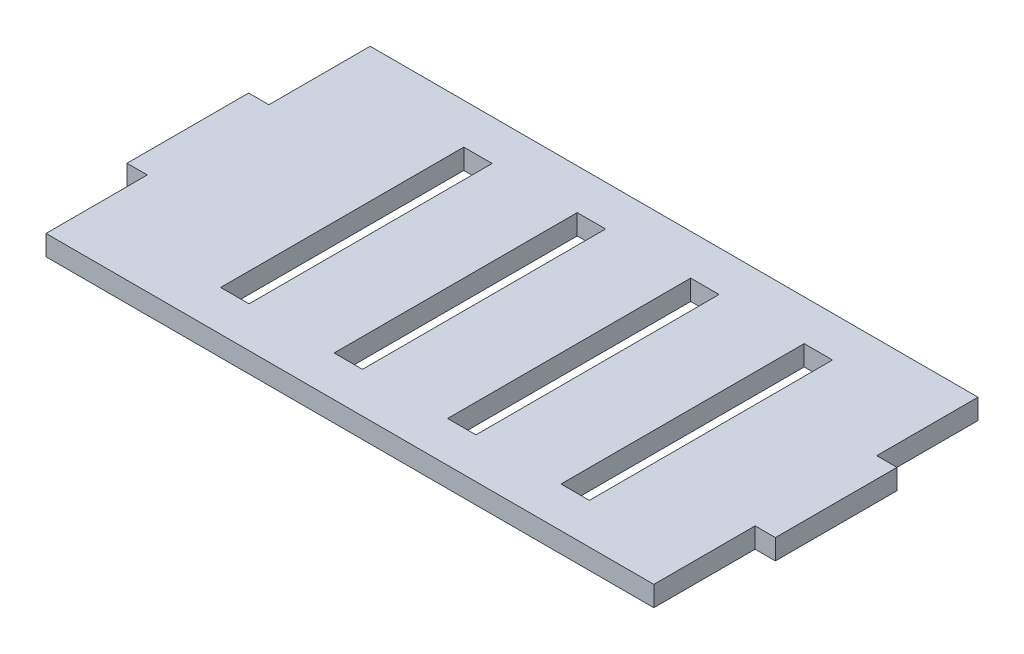
from build123d import *

# Parameters (mm, degrees)
SKETCH1_W           = 190.5
SKETCH1_H           = 101.6
BOSS_EXTRUDE1_DEPTH = 6.35
SKETCH2_W           = 8.89
SKETCH2_H           = 76.2
HOLE_DEPTH          = 6.35
SKETCH3_W           = 38.1
SKETCH3_H           = 6.35
TAB1_DEPTH          = 6.35
SKETCH4_W           = 38.1
SKETCH4_H           = 6.35
TAB2_DEPTH          = 6.35


with BuildPart() as part:
    # Sketch1 → Boss-Extrude1 (new body)
    with BuildSketch(Plane(origin=(0, 0, 0), x_dir=(1, 0, 0), z_dir=(0, 1, 0))):
        Rectangle(SKETCH1_W, SKETCH1_H)
    extrude(amount=BOSS_EXTRUDE1_DEPTH)

    # Sketch2 → hole (cut)
    with BuildSketch(Plane(origin=(0, 6.35, 0), x_dir=(1, 0, 0), z_dir=(0, 1, 0))):
        with Locations((-48.768, 0)):
            Rectangle(SKETCH2_W, SKETCH2_H)
        with Locations((-13.208, 0)):
            Rectangle(SKETCH2_W, SKETCH2_H)
        with Locations((22.352, 0)):
            Rectangle(SKETCH2_W, SKETCH2_H)
        with Locations((57.912, 0)):
            Rectangle(SKETCH2_W, SKETCH2_H)
    extrude(amount=-HOLE_DEPTH, mode=Mode.SUBTRACT)

    # Sketch3 → tab1 (add)
    with BuildSketch(Plane.ZY.offset(95.25)):
        with Locations((0, 3.175)):
            Rectangle(SKETCH3_W, SKETCH3_H)
    extrude(amount=TAB1_DEPTH)

    # Sketch4 → tab2 (add)
    with BuildSketch(Plane(origin=(95.25, 0, 0), x_dir=(0, 0, -1), z_dir=(1, 0, 0))):
        with Locations((0, 3.175)):
            Rectangle(SKETCH4_W, SKETCH4_H)
    extrude(amount=TAB2_DEPTH)


solid = part.part
